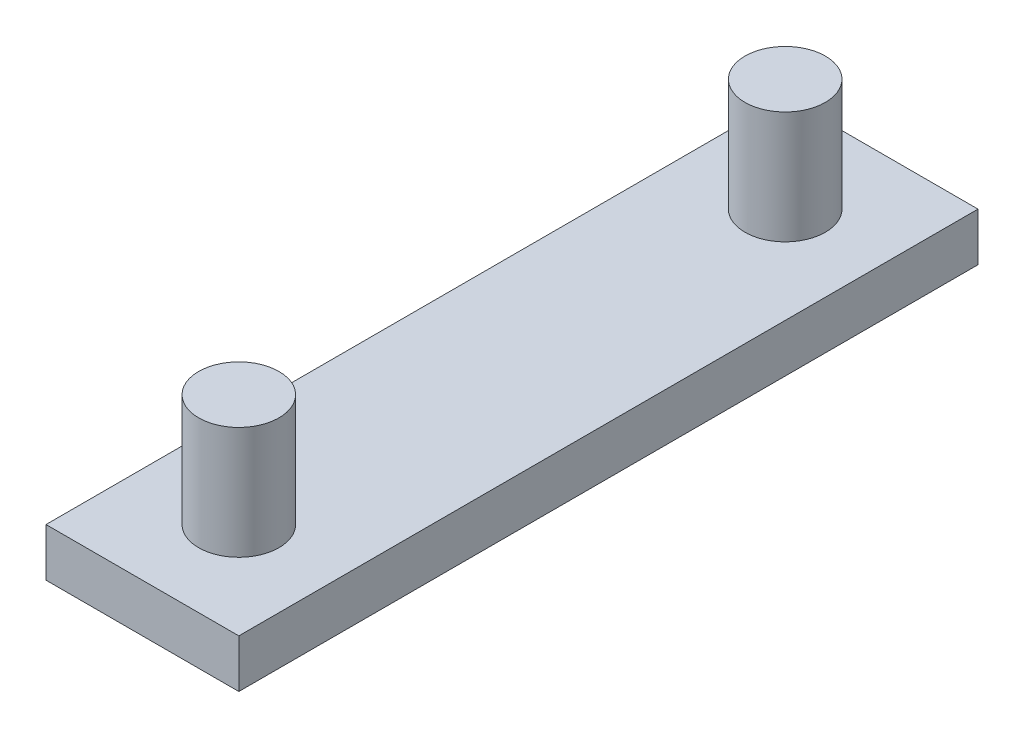
from build123d import *

# Parameters (mm, degrees)
SKETCH3_R             = 2.5
BOSS_EXTRUDE4_DEPTH   = 10
BOSS_EXTRUDE4_2_DEPTH = 10
SKETCH2_W             = 12
SKETCH2_H             = 46
BOSS_EXTRUDE5_DEPTH   = 3


with BuildPart() as part:
    # Sketch3 → Boss-Extrude4 (new body)
    with BuildSketch(Plane(origin=(0, 0, 0), x_dir=(1, 0, 0), z_dir=(0, 1, 0))):
        with Locations((-0.169934853, 17.143306367)):
            Circle(SKETCH3_R)
    extrude(amount=BOSS_EXTRUDE4_DEPTH)



with BuildPart() as body_2:
    # Sketch3 → Boss-Extrude4 2 (new body)
    with BuildSketch(Plane(origin=(0, 0, 0), x_dir=(1, 0, 0), z_dir=(0, 1, 0))):
        with Locations((-0.169934853, -16.856693633)):
            Circle(SKETCH3_R)
    extrude(amount=BOSS_EXTRUDE4_2_DEPTH)


with BuildPart() as part_1:
    add(part.part)

    add(body_2.part)  # Boss-Extrude5 merges body 2
    # Sketch2 → Boss-Extrude5 (add)
    with BuildSketch(Plane(origin=(0, 0, 0), x_dir=(1, 0, 0), z_dir=(0, 1, 0))):
        with Locations((-0.169934853, 0.143306367)):
            Rectangle(SKETCH2_W, SKETCH2_H)
    extrude(amount=BOSS_EXTRUDE5_DEPTH)


solid = part_1.part
